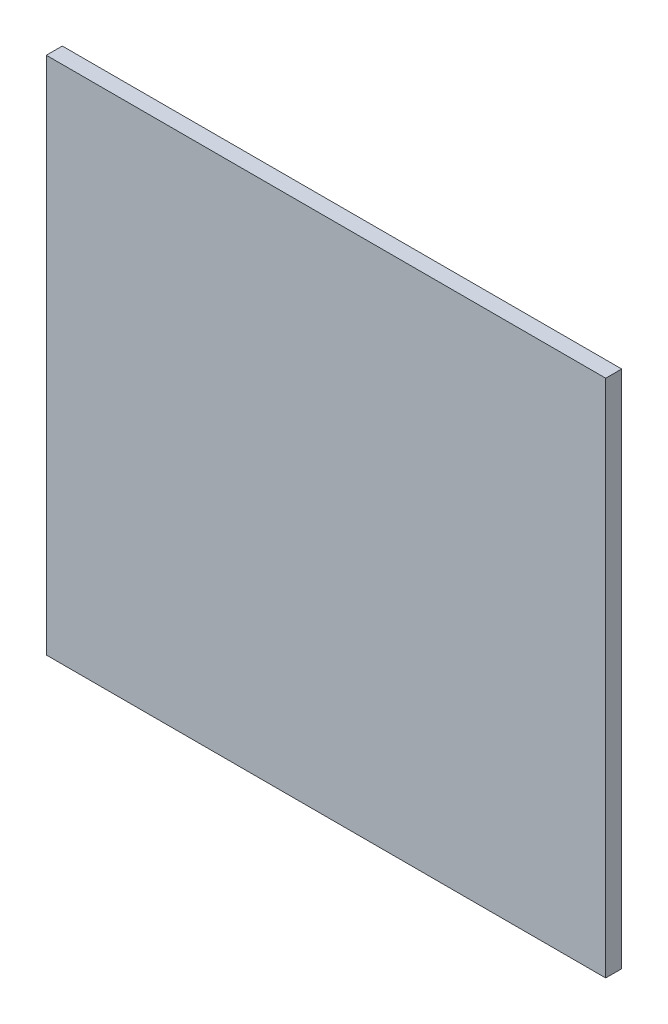
from build123d import *

# Parameters (mm, degrees)
SKETCH1_W           = 140
SKETCH1_H           = 130
BOSS_EXTRUDE1_DEPTH = 4


with BuildPart() as part:
    # Sketch1 → Boss-Extrude1 (new body)
    with BuildSketch(Plane.XY):
        Rectangle(SKETCH1_W, SKETCH1_H)
    extrude(amount=BOSS_EXTRUDE1_DEPTH)


solid = part.part
